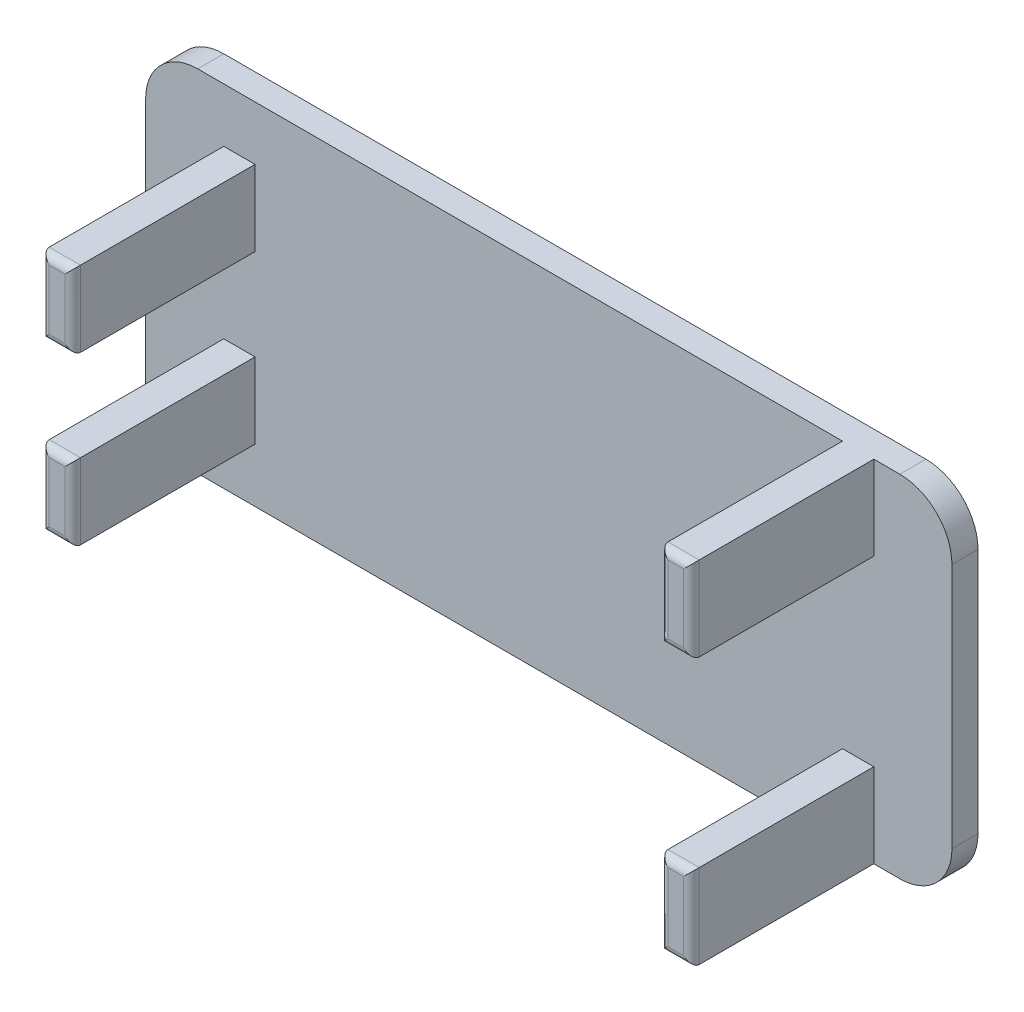
from build123d import *

# Parameters (mm, degrees)
EXTRUDE_1_DEPTH     = 1
SKETCH_2_W          = 1.2
SKETCH_2_H          = 13.45
SKETCH_2_H_2        = 9.3
EXTRUDE_2_DEPTH     = 7
CUT_EXTRUDE_1_REACH = 29.95
SKETCH_3_W          = 7
SKETCH_3_H          = 7
CUT_EXTRUDE_2_REACH = 29.95
SKETCH_4_W          = 7
SKETCH_4_H          = 3.5
FILLET_1_R          = 0.3


with BuildPart() as part:
    # 草图1 → 凸台-拉伸1 (new body)
    with BuildSketch(Plane.XY):
        with BuildLine():
            Line((2, 0), (28.95, 0))
            ThreePointArc((28.95, 0), (30.364213562, 0.585786438), (30.95, 2))
            Line((30.95, 2), (30.95, 11.45))
            ThreePointArc((30.95, 11.45), (30.364213562, 12.864213562), (28.95, 13.45))
            Line((28.95, 13.45), (2, 13.45))
            ThreePointArc((2, 13.45), (0.585786438, 12.864213562), (0, 11.45))
            Line((0, 11.45), (0, 2))
            ThreePointArc((0, 2), (0.585786438, 0.585786438), (2, 0))
        make_face()
    extrude(amount=EXTRUDE_1_DEPTH)

    # 草图2 → 凸台-拉伸2 (add)
    with BuildSketch(Plane.XY.offset(1)):
        with Locations((27.35, 6.725)):
            Rectangle(SKETCH_2_W, SKETCH_2_H)
        with Locations((3.6, 6.725)):
            Rectangle(SKETCH_2_W, SKETCH_2_H_2)
    extrude(amount=EXTRUDE_2_DEPTH)

    # 草图3 → 切除-拉伸1 (cut, up to next)
    with BuildSketch(Plane(origin=(27.95, 0, 0), x_dir=(0, 0, -1), z_dir=(1, 0, 0)), mode=Mode.PRIVATE) as cut_extrude_1_sk1:
        with Locations((-4.5, 6.725)):
            Rectangle(SKETCH_3_W, SKETCH_3_H)
    cut_extrude_1_tool1 = extrude(cut_extrude_1_sk1.sketch, amount=-CUT_EXTRUDE_1_REACH, mode=Mode.PRIVATE) & part.part
    add(cut_extrude_1_tool1.solids().sort_by_distance((27.95, 6.725, 4.5))[0], mode=Mode.SUBTRACT)

    # 草图4 → 切除-拉伸2 (cut, up to next)
    with BuildSketch(Plane.ZY.offset(-3), mode=Mode.PRIVATE) as cut_extrude_2_sk1:
        with Locations((4.5, 6.725)):
            Rectangle(SKETCH_4_W, SKETCH_4_H)
    cut_extrude_2_tool1 = extrude(cut_extrude_2_sk1.sketch, amount=-CUT_EXTRUDE_2_REACH, mode=Mode.PRIVATE) & part.part
    add(cut_extrude_2_tool1.solids().sort_by_distance((3, 6.725, 4.5))[0], mode=Mode.SUBTRACT)

    # 圆角1
    fillet_1_edges = [part.edges().sort_by_distance(p)[0] for p in [
        (26.75, 11.8375, 8),
        (27.35, 0, 8),
        (27.95, 1.6125, 8),
        (27.35, 13.45, 8),
        (3, 9.925, 8),
        (3.6, 2.075, 8),
        (4.2, 3.525, 8),
        (3.6, 11.375, 8),
        (26.75, 1.6125, 8),
        (27.95, 11.8375, 8),
        (27.35, 3.225, 8),
        (27.35, 10.225, 8),
        (3, 3.525, 8),
        (4.2, 9.925, 8),
        (3.6, 8.475, 8),
        (3.6, 4.975, 8),
    ]]
    fillet(fillet_1_edges, radius=FILLET_1_R)


solid = part.part
